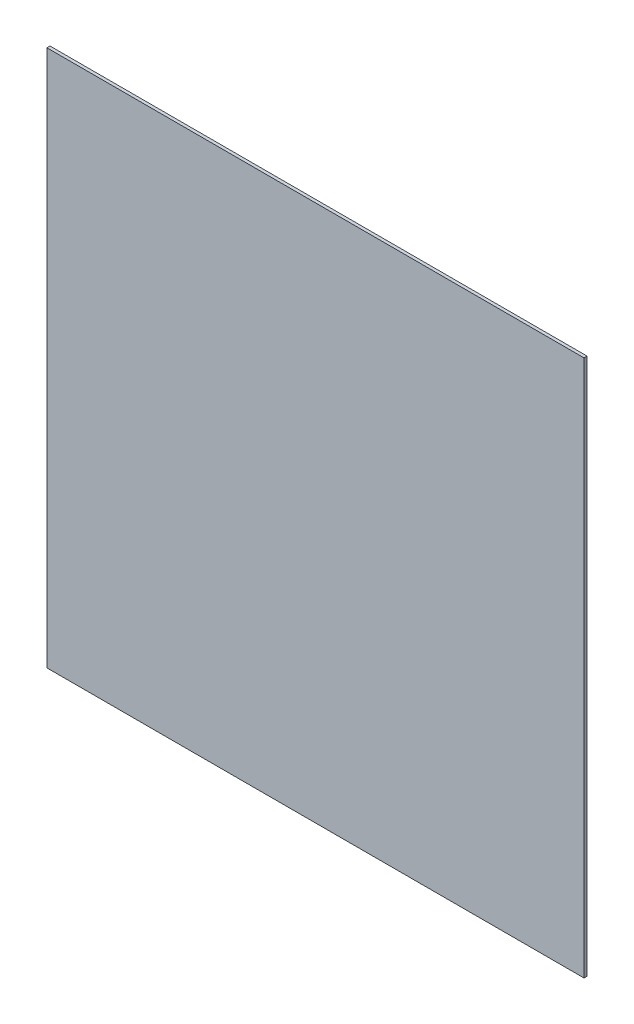
from build123d import *

# Parameters (mm, degrees)
SKETCH1_W           = 3660
SKETCH1_H           = 3660
BOSS_EXTRUDE1_DEPTH = 21


with BuildPart() as part:
    # Sketch1 → Boss-Extrude1 (new body)
    with BuildSketch(Plane.XY):
        Rectangle(SKETCH1_W, SKETCH1_H)
    extrude(amount=BOSS_EXTRUDE1_DEPTH)


solid = part.part
